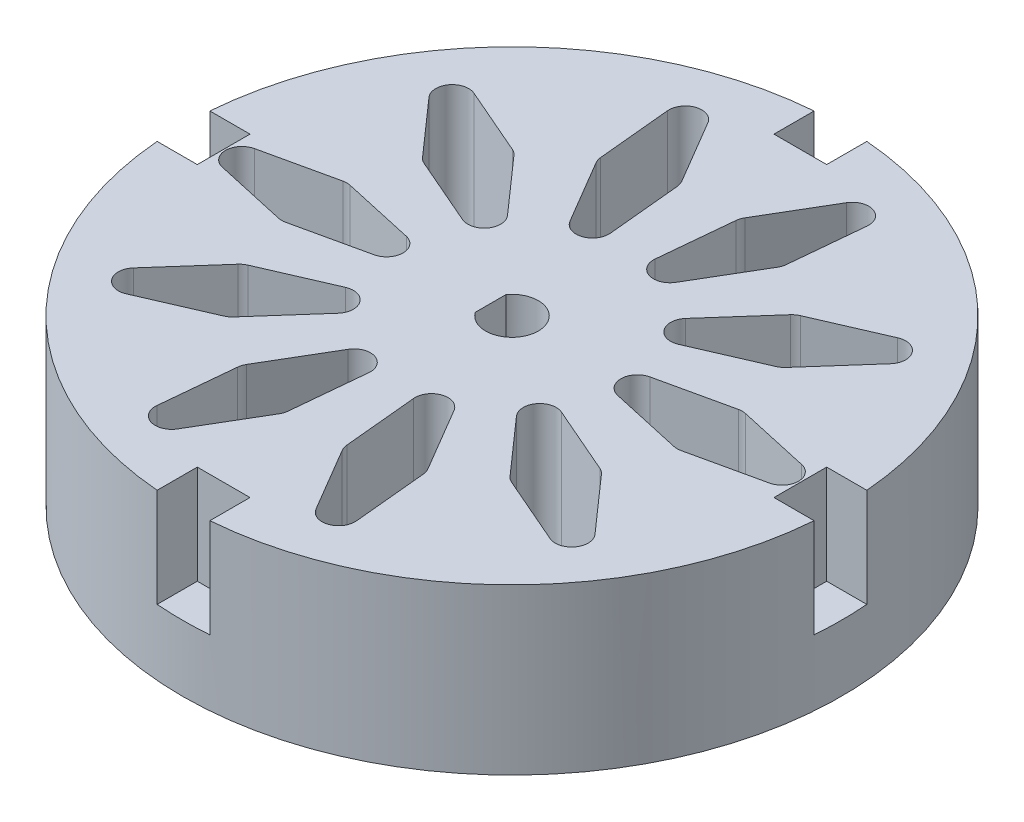
from build123d import *

# Parameters (mm, degrees)
SKETCH_1_R               = 20
SKETCH_1_R_2             = 4
EXTRUDE_1_DEPTH          = 10
SKETCH_4_R               = 20
EXTRUDE_2_DEPTH          = 6
SKETCH_5_R               = 1.6
CUT_EXTRUDE_2_DEPTH      = 5
CUT_EXTRUDE_2_DEPTH_BACK = 7
CUT_EXTRUDE_3_DEPTH      = 1
CUT_EXTRUDE_3_DEPTH_BACK = 11
SKETCH_8_W               = 3.2
SKETCH_8_H               = 5
SKETCH_8_W_2             = 5
SKETCH_8_H_2             = 3.2
CUT_EXTRUDE_4_DEPTH      = 6
SKETCH_9_R               = 3
CUT_EXTRUDE_5_DEPTH      = 2
SKETCH_11_R              = 4
EXTRUDE_3_DEPTH          = 4
SKETCH_12_R              = 3
EXTRUDE_4_DEPTH          = 2
SKETCH_13_R              = 1.6
EXTRUDE_5_DEPTH          = 2


with BuildPart() as part:
    # Эскиз1 → Бобышка-Вытянуть1 (new body)
    with BuildSketch(Plane(origin=(0, 0, 0), x_dir=(1, 0, 0), z_dir=(0, 1, 0))):
        Circle(SKETCH_1_R)
        Circle(SKETCH_1_R_2, mode=Mode.SUBTRACT)
    extrude(amount=EXTRUDE_1_DEPTH)

    # Эскиз4 → Бобышка-Вытянуть2 (add)
    with BuildSketch(Plane.XZ):
        Circle(SKETCH_4_R)
    extrude(amount=-EXTRUDE_2_DEPTH)

    # Эскиз5 → Вырез-Вытянуть2 (cut, two sides)
    with BuildSketch(Plane(origin=(0, 6, 0), x_dir=(1, 0, 0), z_dir=(0, 1, 0))) as cut_extrude_2_sk:
        Circle(SKETCH_5_R)
    extrude(amount=CUT_EXTRUDE_2_DEPTH, mode=Mode.SUBTRACT)
    extrude(cut_extrude_2_sk.sketch, amount=-CUT_EXTRUDE_2_DEPTH_BACK, mode=Mode.SUBTRACT)

    # Эскиз6 → Вырез-Вытянуть3 (cut, two sides)
    with BuildSketch(Plane.XZ) as cut_extrude_3_sk:
        with BuildLine():
            Line((-7.392842, 0.976187), (-11.78307, 1.951793))
            ThreePointArc((-11.78307, 1.951793), (-12, 1.975606), (-12.21693, 1.951793))
            Line((-12.21693, 1.951793), (-16.607158, 0.976187))
            ThreePointArc((-16.607158, 0.976187), (-17.390228, 0), (-16.607158, -0.976187))
            Line((-16.607158, -0.976187), (-12.21693, -1.951793))
            ThreePointArc((-12.21693, -1.951793), (-12, -1.975606), (-11.78307, -1.951793))
            Line((-11.78307, -1.951793), (-7.392842, -0.976187))
            ThreePointArc((-7.392842, -0.976187), (-6.609772, 0), (-7.392842, 0.976187))
        make_face()
        with BuildLine():
            Line((-5.407146, 5.135155), (-8.385468, 8.504948))
            ThreePointArc((-8.385468, 8.504948), (-8.546972, 8.651722), (-8.736469, 8.759965))
            Line((-8.736469, 8.759965), (-12.861685, 10.551195))
            ThreePointArc((-12.861685, 10.551195), (-14.06899, 10.221719), (-14.009262, 8.971691))
            Line((-14.009262, 8.971691), (-11.03094, 5.601898))
            ThreePointArc((-11.03094, 5.601898), (-10.869436, 5.455124), (-10.679939, 5.346881))
            Line((-10.679939, 5.346881), (-6.554723, 3.555651))
            ThreePointArc((-6.554723, 3.555651), (-5.347418, 3.885127), (-5.407146, 5.135155))
        make_face()
        with BuildLine():
            Line((-1.356105, 7.332669), (-1.784903, 11.809502))
            ThreePointArc((-1.784903, 11.809502), (-1.829291, 12.023174), (-1.918973, 12.222129))
            Line((-1.918973, 12.222129), (-4.203485, 16.096004))
            ThreePointArc((-4.203485, 16.096004), (-5.373876, 16.539089), (-6.060303, 15.492688))
            Line((-6.060303, 15.492688), (-5.631505, 11.015854))
            ThreePointArc((-5.631505, 11.015854), (-5.587117, 10.802182), (-5.497434, 10.603228))
            Line((-5.497434, 10.603228), (-3.212923, 6.729352))
            ThreePointArc((-3.212923, 6.729352), (-2.042532, 6.286267), (-1.356105, 7.332669))
        make_face()
        with BuildLine():
            Line((3.212923, 6.729352), (5.497434, 10.603228))
            ThreePointArc((5.497434, 10.603228), (5.587117, 10.802182), (5.631505, 11.015854))
            Line((5.631505, 11.015854), (6.060303, 15.492688))
            ThreePointArc((6.060303, 15.492688), (5.373876, 16.539089), (4.203485, 16.096004))
            Line((4.203485, 16.096004), (1.918973, 12.222129))
            ThreePointArc((1.918973, 12.222129), (1.829291, 12.023174), (1.784903, 11.809502))
            Line((1.784903, 11.809502), (1.356105, 7.332669))
            ThreePointArc((1.356105, 7.332669), (2.042532, 6.286267), (3.212923, 6.729352))
        make_face()
        with BuildLine():
            Line((6.554723, 3.555651), (10.679939, 5.346881))
            ThreePointArc((10.679939, 5.346881), (10.869436, 5.455124), (11.03094, 5.601898))
            Line((11.03094, 5.601898), (14.009262, 8.971691))
            ThreePointArc((14.009262, 8.971691), (14.06899, 10.221719), (12.861685, 10.551195))
            Line((12.861685, 10.551195), (8.736469, 8.759965))
            ThreePointArc((8.736469, 8.759965), (8.546972, 8.651722), (8.385468, 8.504948))
            Line((8.385468, 8.504948), (5.407146, 5.135155))
            ThreePointArc((5.407146, 5.135155), (5.347418, 3.885127), (6.554723, 3.555651))
        make_face()
        with BuildLine():
            Line((7.392842, -0.976187), (11.78307, -1.951793))
            ThreePointArc((11.78307, -1.951793), (12, -1.975606), (12.21693, -1.951793))
            Line((12.21693, -1.951793), (16.607158, -0.976187))
            ThreePointArc((16.607158, -0.976187), (17.390228, 0), (16.607158, 0.976187))
            Line((16.607158, 0.976187), (12.21693, 1.951793))
            ThreePointArc((12.21693, 1.951793), (12, 1.975606), (11.78307, 1.951793))
            Line((11.78307, 1.951793), (7.392842, 0.976187))
            ThreePointArc((7.392842, 0.976187), (6.609772, 0), (7.392842, -0.976187))
        make_face()
        with BuildLine():
            Line((5.407146, -5.135155), (8.385468, -8.504948))
            ThreePointArc((8.385468, -8.504948), (8.546972, -8.651722), (8.736469, -8.759965))
            Line((8.736469, -8.759965), (12.861685, -10.551195))
            ThreePointArc((12.861685, -10.551195), (14.06899, -10.221719), (14.009262, -8.971691))
            Line((14.009262, -8.971691), (11.03094, -5.601898))
            ThreePointArc((11.03094, -5.601898), (10.869436, -5.455124), (10.679939, -5.346881))
            Line((10.679939, -5.346881), (6.554723, -3.555651))
            ThreePointArc((6.554723, -3.555651), (5.347418, -3.885127), (5.407146, -5.135155))
        make_face()
        with BuildLine():
            Line((1.356105, -7.332669), (1.784903, -11.809502))
            ThreePointArc((1.784903, -11.809502), (1.829291, -12.023174), (1.918973, -12.222129))
            Line((1.918973, -12.222129), (4.203485, -16.096004))
            ThreePointArc((4.203485, -16.096004), (5.373876, -16.539089), (6.060303, -15.492688))
            Line((6.060303, -15.492688), (5.631505, -11.015854))
            ThreePointArc((5.631505, -11.015854), (5.587117, -10.802182), (5.497434, -10.603228))
            Line((5.497434, -10.603228), (3.212923, -6.729352))
            ThreePointArc((3.212923, -6.729352), (2.042532, -6.286267), (1.356105, -7.332669))
        make_face()
        with BuildLine():
            Line((-3.212923, -6.729352), (-5.497434, -10.603228))
            ThreePointArc((-5.497434, -10.603228), (-5.587117, -10.802182), (-5.631505, -11.015854))
            Line((-5.631505, -11.015854), (-6.060303, -15.492688))
            ThreePointArc((-6.060303, -15.492688), (-5.373876, -16.539089), (-4.203485, -16.096004))
            Line((-4.203485, -16.096004), (-1.918973, -12.222129))
            ThreePointArc((-1.918973, -12.222129), (-1.829291, -12.023174), (-1.784903, -11.809502))
            Line((-1.784903, -11.809502), (-1.356105, -7.332669))
            ThreePointArc((-1.356105, -7.332669), (-2.042532, -6.286267), (-3.212923, -6.729352))
        make_face()
        with BuildLine():
            Line((-6.554723, -3.555651), (-10.679939, -5.346881))
            ThreePointArc((-10.679939, -5.346881), (-10.869436, -5.455124), (-11.03094, -5.601898))
            Line((-11.03094, -5.601898), (-14.009262, -8.971691))
            ThreePointArc((-14.009262, -8.971691), (-14.06899, -10.221719), (-12.861685, -10.551195))
            Line((-12.861685, -10.551195), (-8.736469, -8.759965))
            ThreePointArc((-8.736469, -8.759965), (-8.546972, -8.651722), (-8.385468, -8.504948))
            Line((-8.385468, -8.504948), (-5.407146, -5.135155))
            ThreePointArc((-5.407146, -5.135155), (-5.347418, -3.885127), (-6.554723, -3.555651))
        make_face()
    extrude(amount=CUT_EXTRUDE_3_DEPTH, mode=Mode.SUBTRACT)
    extrude(cut_extrude_3_sk.sketch, amount=-CUT_EXTRUDE_3_DEPTH_BACK, mode=Mode.SUBTRACT)

    # Эскиз8 → Вырез-Вытянуть4 (cut)
    with BuildSketch(Plane(origin=(0, 10, 0), x_dir=(1, 0, 0), z_dir=(0, 1, 0))):
        with Locations((0, 20)):
            Rectangle(SKETCH_8_W, SKETCH_8_H)
        with Locations((-20, 0)):
            Rectangle(SKETCH_8_W_2, SKETCH_8_H_2)
        with Locations((20, 0)):
            Rectangle(SKETCH_8_W_2, SKETCH_8_H_2)
        with Locations((0, -20)):
            Rectangle(SKETCH_8_W, SKETCH_8_H)
    extrude(amount=-CUT_EXTRUDE_4_DEPTH, mode=Mode.SUBTRACT)

    # Эскиз9 → Вырез-Вытянуть5 (cut)
    with BuildSketch(Plane.XZ):
        Circle(SKETCH_9_R)
    extrude(amount=-CUT_EXTRUDE_5_DEPTH, mode=Mode.SUBTRACT)

    # Эскиз11 → Бобышка-Вытянуть3 (add)
    with BuildSketch(Plane(origin=(0, 6, 0), x_dir=(1, 0, 0), z_dir=(0, 1, 0))):
        Circle(SKETCH_11_R)
        with BuildLine():
            Line((-1.3, 0.932738), (-1.3, -0.932738))
            ThreePointArc((-1.3, -0.932738), (1.6, 0), (-1.3, 0.932738))
        make_face(mode=Mode.SUBTRACT)
    extrude(amount=EXTRUDE_3_DEPTH)

    # Эскиз12 → Бобышка-Вытянуть4 (add)
    with BuildSketch(Plane.XZ.offset(-2)):
        Circle(SKETCH_12_R)
    extrude(amount=EXTRUDE_4_DEPTH)

    # Эскиз13 → Бобышка-Вытянуть5 (add)
    with BuildSketch(Plane(origin=(0, 2, 0), x_dir=(1, 0, 0), z_dir=(0, 1, 0))):
        Circle(SKETCH_13_R)
    extrude(amount=EXTRUDE_5_DEPTH)


solid = part.part
